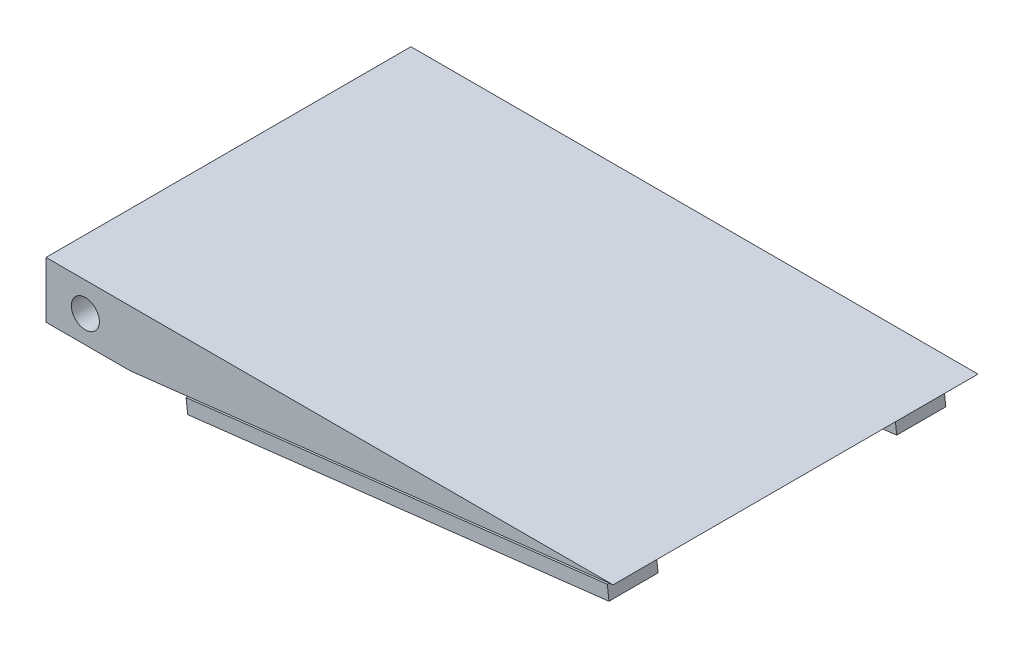
from build123d import *

# Parameters (mm, degrees)
SKETCH1_W           = 513.08
SKETCH1_H           = 330.2
BOSS_EXTRUDE1_DEPTH = 50.8
SKETCH2_R           = 12.7
CUT_EXTRUDE1_DEPTH  = 331.2
SKETCH3_W           = 382.967058901
SKETCH3_H           = 19.05
BOSS_EXTRUDE2_DEPTH = 12.7
SKETCH4_W           = 383.722022032
SKETCH4_H           = 44.45
BOSS_EXTRUDE3_DEPTH = 12.7


with BuildPart() as part:
    # Sketch1 → Boss-Extrude1 (new body)
    with BuildSketch(Plane(origin=(0, 0, 0), x_dir=(1, 0, 0), z_dir=(0, 1, 0))):
        with Locations((28.712036474, 1.505471125)):
            Rectangle(SKETCH1_W, SKETCH1_H)
    extrude(amount=BOSS_EXTRUDE1_DEPTH)

    # Sketch2 → Cut-Extrude1 (cut, through all)
    with BuildSketch(Plane.XY.offset(163.594528875)):
        with Locations((-192.209486062, 24.51392069)):
            Circle(SKETCH2_R)
        Polygon((-151.627963526, 0), (285.252036474, 50.8), (285.252036474, 0), align=None)
    extrude(amount=-CUT_EXTRUDE1_DEPTH, mode=Mode.SUBTRACT)

    # Sketch3 → Boss-Extrude2 (add)
    with BuildSketch(Plane(origin=(-2.022784999, 17.395950991, 0), x_dir=(0.99330738, 0.115500858, 0), z_dir=(0.115500858, -0.99330738, 0))):
        with Locations((77.492959748, -131.680471125)):
            Rectangle(SKETCH3_W, SKETCH3_H)
    boss_extrude2 = extrude(amount=BOSS_EXTRUDE2_DEPTH)

    # Sketch4 → Boss-Extrude3 (add)
    with BuildSketch(Plane(origin=(-0.5559241, 4.780947262, 0), x_dir=(0.99330738, 0.115500858, 0), z_dir=(0.115500858, -0.99330738, 0))):
        with Locations((77.870441313, -131.680471125)):
            Rectangle(SKETCH4_W, SKETCH4_H)
    boss_extrude3 = extrude(amount=BOSS_EXTRUDE3_DEPTH)

    # Mirror1: Boss-Extrude2, Boss-Extrude3 across plane
    add(boss_extrude2.mirror(Plane.XY.offset(-1.505471125)))
    add(boss_extrude3.mirror(Plane.XY.offset(-1.505471125)))


solid = part.part
